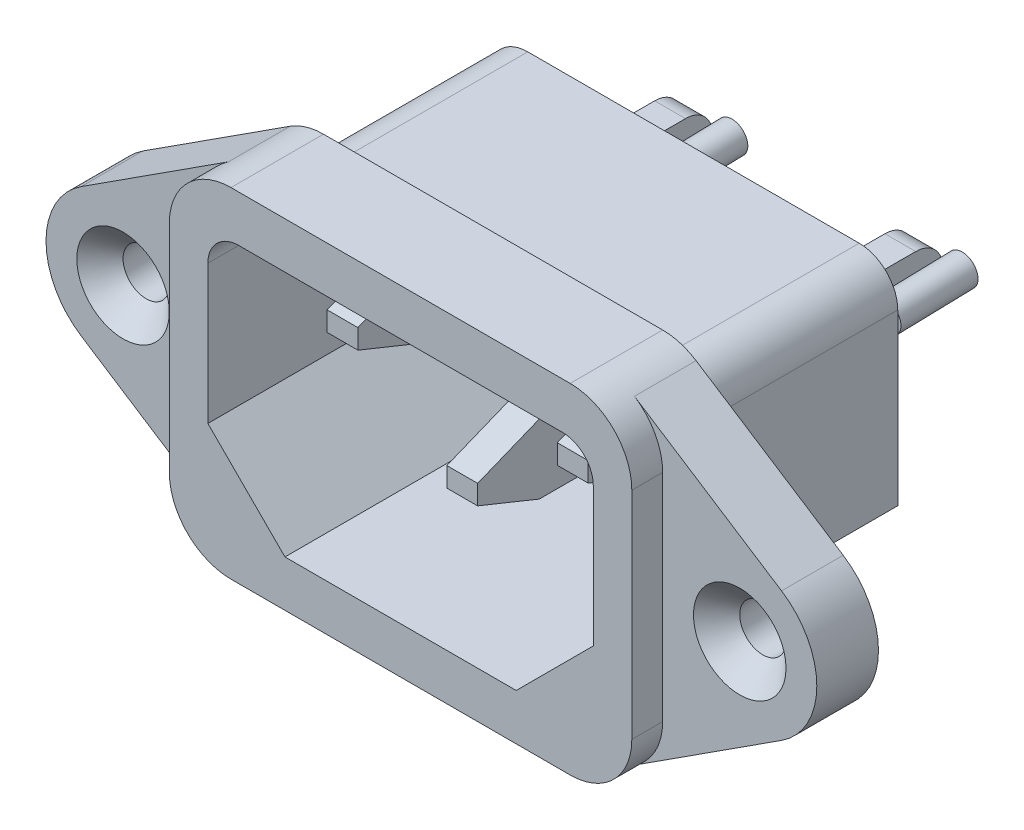
from build123d import *

# Parameters (mm, degrees)
BASE_DEPTH                       = 4
BOSS_EXTRUDE2_DEPTH              = 2
SKETCH3_W                        = 26.5
SKETCH3_H                        = 18.5
BOSS_EXTRUDE3_DEPTH              = 13
SKETCH4_W                        = 25
SKETCH4_H                        = 16
CUT_EXTRUDE1_DEPTH               = 17
GND_DEPTH                        = 2
EXTRUDE_L_DEPTH                  = 2
EXTRUDE_N_DEPTH                  = 2
MOUNT_3_0_3_DIAMETER_HOLE1_D     = 3
MOUNT_3_0_3_DIAMETER_HOLE1_DEPTH = 25
CHAMFER1_SIZE                    = 5
CHAMFER2_SIZE                    = 1.692162145
CHAMFER2_PART_2_SIZE             = 1.692162145
CHAMFER2_PART_3_SIZE             = 1.692162145
CHAMFER3_SIZE                    = 1.5
FILLET1_R                        = 2
FILLET2_R                        = 2.5
SOLDER_DEPTH                     = 2
SOLDER_DEPTH_BACK                = 3
SKETCH13_R                       = 1
SOLDER_2_DEPTH                   = 2
SOLDER_2_DEPTH_BACK              = 3
SOLDER_3_DEPTH                   = 2
SOLDER_3_DEPTH_BACK              = 3


with BuildPart() as part:
    # Sketch1 → Base (new body)
    with BuildSketch(Plane(origin=(0, 0, 0), x_dir=(-1, 0, 0), z_dir=(0, 0, -1))):
        with BuildLine():
            Line((-13.169375903, 10.360626161), (-22.711719879, 4.200782701))
            ThreePointArc((-22.711719879, 4.200782701), (-25, 0), (-22.711719879, -4.200782701))
            Line((-22.711719879, -4.200782701), (-13.169375903, -10.360626161))
            ThreePointArc((-13.169375903, -10.360626161), (-12.130817261, -10.83682842), (-11, -11))
            Line((-11, -11), (11, -11))
            ThreePointArc((11, -11), (12.130817261, -10.83682842), (13.169375903, -10.360626161))
            Line((13.169375903, -10.360626161), (22.711719879, -4.200782701))
            ThreePointArc((22.711719879, -4.200782701), (25, 0), (22.711719879, 4.200782701))
            Line((22.711719879, 4.200782701), (13.169375903, 10.360626161))
            ThreePointArc((13.169375903, 10.360626161), (12.130817261, 10.83682842), (11, 11))
            Line((11, 11), (-11, 11))
            ThreePointArc((-11, 11), (-12.130817261, 10.83682842), (-13.169375903, 10.360626161))
        make_face()
    extrude(amount=-BASE_DEPTH)

    # Sketch2 → Boss-Extrude2 (add)
    with BuildSketch(Plane.XY.offset(4)):
        with BuildLine():
            Line((11, -11), (-11, -11))
            ThreePointArc((-11, -11), (-13.828427125, -9.828427125), (-15, -7))
            Line((-15, -7), (-15, 7))
            ThreePointArc((-15, 7), (-13.828427125, 9.828427125), (-11, 11))
            Line((-11, 11), (11, 11))
            ThreePointArc((11, 11), (13.828427125, 9.828427125), (15, 7))
            Line((15, 7), (15, -7))
            ThreePointArc((15, -7), (13.828427125, -9.828427125), (11, -11))
        make_face()
    extrude(amount=BOSS_EXTRUDE2_DEPTH)

    # Sketch3 → Boss-Extrude3 (add)
    with BuildSketch(Plane(origin=(0, 0, 0), x_dir=(-1, 0, 0), z_dir=(0, 0, -1))):
        Rectangle(SKETCH3_W, SKETCH3_H)
    extrude(amount=BOSS_EXTRUDE3_DEPTH)

    # Sketch4 → Cut-Extrude1 (cut)
    with BuildSketch(Plane.XY.offset(6)):
        Rectangle(SKETCH4_W, SKETCH4_H)
    extrude(amount=-CUT_EXTRUDE1_DEPTH, mode=Mode.SUBTRACT)

    # Sketch5 → GND (add)
    with BuildSketch(Plane(origin=(1, 0, 0), x_dir=(0, 0, -1), z_dir=(1, 0, 0))):
        with BuildLine():
            Line((2, 0.000898958), (-3.56894542, -2.249101042))
            Line((-3.56894542, -2.249101042), (2, -4.499101042))
            Line((2, -4.499101042), (13, -4.499101042))
            Line((13, -4.499101042), (13, -3.867648726))
            Line((13, -3.867648726), (19.381452315, -3.867648726))
            ThreePointArc((19.381452315, -3.867648726), (21, -2.249101042), (19.381452315, -0.630553357))
            Line((19.381452315, -0.630553357), (13, -0.630553357))
            Line((13, -0.630553357), (13, 0.000898958))
            Line((13, 0.000898958), (2, 0.000898958))
        make_face()
    extrude(amount=-GND_DEPTH)

    # Sketch6 → Extrude L (add)
    with BuildSketch(Plane(origin=(-6.767244159, 0, 0), x_dir=(0, 0, -1), z_dir=(1, 0, 0))):
        with BuildLine():
            Line((2, 4.865233769), (-3.56894542, 2.615233769))
            Line((-3.56894542, 2.615233769), (2, 0.365233769))
            Line((2, 0.365233769), (12.665711597, 0.365233769))
            Line((12.665711597, 0.365233769), (12.665711597, 0.865233769))
            Line((12.665711597, 0.865233769), (19.25, 0.865233769))
            ThreePointArc((19.25, 0.865233769), (21, 2.615233769), (19.25, 4.365233769))
            Line((19.25, 4.365233769), (12.665711597, 4.365233769))
            Line((12.665711597, 4.365233769), (12.665711597, 4.865233769))
            Line((12.665711597, 4.865233769), (2, 4.865233769))
        make_face()
    extrude(amount=-EXTRUDE_L_DEPTH)

    # Sketch7 → Extrude N (add)
    with BuildSketch(Plane(origin=(8.165740402, 0, 0), x_dir=(0, 0, -1), z_dir=(1, 0, 0))):
        with BuildLine():
            Line((2, 4.865233769), (-3.56894542, 2.615233769))
            Line((-3.56894542, 2.615233769), (2, 0.365233769))
            Line((2, 0.365233769), (13, 0.365233769))
            Line((13, 0.365233769), (13, 0.865233769))
            Line((13, 0.865233769), (19.25, 0.865233769))
            ThreePointArc((19.25, 0.865233769), (21, 2.615233769), (19.25, 4.365233769))
            Line((19.25, 4.365233769), (13, 4.365233769))
            Line((13, 4.365233769), (13, 4.865233769))
            Line((13, 4.865233769), (2, 4.865233769))
        make_face()
    extrude(amount=-EXTRUDE_N_DEPTH)

    # Mount Ø3.0 (3) Diameter Hole1
    with Locations(Plane.XY.offset(4)):
        with Locations((-20, 0), (20, 0)):
            Hole(MOUNT_3_0_3_DIAMETER_HOLE1_D / 2, depth=MOUNT_3_0_3_DIAMETER_HOLE1_DEPTH)

    # Chamfer1
    chamfer1_edges = [part.edges().sort_by_distance(p)[0] for p in [
        (13.25, -9.25, -6.5),
        (-13.25, -9.25, -6.5),
        (12.5, -8, -2.5),
        (-12.5, -8, -2.5),
    ]]
    chamfer(chamfer1_edges, length=CHAMFER1_SIZE)

    # Chamfer2
    chamfer2_edges = [part.edges().sort_by_distance(p)[0] for p in [
        (0, -2.249101042, 3.56894542),
    ]]
    chamfer(chamfer2_edges, length=CHAMFER2_SIZE)

    # Chamfer2 part 2
    chamfer2_part_2_edges = [part.edges().sort_by_distance(p)[0] for p in [
        (-7.767244159, 2.615233769, 3.56894542),
    ]]
    chamfer(chamfer2_part_2_edges, length=CHAMFER2_PART_2_SIZE)

    # Chamfer2 part 3
    chamfer2_part_3_edges = [part.edges().sort_by_distance(p)[0] for p in [
        (7.165740402, 2.615233769, 3.56894542),
    ]]
    chamfer(chamfer2_part_3_edges, length=CHAMFER2_PART_3_SIZE)

    # Chamfer3
    chamfer3_edges = [part.edges().sort_by_distance(p)[0] for p in [
        (-18.5, 0, 4),
        (21.5, 0, 4),
    ]]
    chamfer(chamfer3_edges, length=CHAMFER3_SIZE)

    # Fillet1
    fillet1_edges = [part.edges().sort_by_distance(p)[0] for p in [
        (12.5, 8, -2.5),
        (-12.5, 8, -2.5),
    ]]
    fillet(fillet1_edges, radius=FILLET1_R)

    # Fillet2
    fillet2_edges = [part.edges().sort_by_distance(p)[0] for p in [
        (-13.25, 9.25, -6.5),
        (13.25, 9.25, -6.5),
    ]]
    fillet(fillet2_edges, radius=FILLET2_R)


with BuildPart() as body_2:
    # Sketch13 → Solder (new, two sides: drawn at the far end of the back side and taken through both)
    with BuildSketch(Plane(origin=(0, -0.008351756, -19.365080553), x_dir=(-1, 0, 0), z_dir=(0, 0.026303529294603365, -0.9996540023161254)).offset(-SOLDER_DEPTH_BACK)):
        with Locations((-9.165740402, 2.790101854)):
            Circle(SKETCH13_R)
    extrude(amount=SOLDER_DEPTH + SOLDER_DEPTH_BACK)


with BuildPart() as body_3:
    # Sketch13 → Solder 2 (new, two sides: drawn at the far end of the back side and taken through both)
    with BuildSketch(Plane(origin=(0, -0.008351756, -19.365080553), x_dir=(-1, 0, 0), z_dir=(0, 0.026303529294603365, -0.9996540023161254)).offset(-SOLDER_2_DEPTH_BACK)):
        with Locations((5.767244159, 2.790101854)):
            Circle(SKETCH13_R)
    extrude(amount=SOLDER_2_DEPTH + SOLDER_2_DEPTH_BACK)


with BuildPart() as body_4:
    # Sketch13 → Solder 3 (new, two sides: drawn at the far end of the back side and taken through both)
    with BuildSketch(Plane(origin=(0, -0.008351756, -19.365080553), x_dir=(-1, 0, 0), z_dir=(0, 0.026303529294603365, -0.9996540023161254)).offset(-SOLDER_3_DEPTH_BACK)):
        with Locations((-2, -2.072549909)):
            Circle(SKETCH13_R)
    extrude(amount=SOLDER_3_DEPTH + SOLDER_3_DEPTH_BACK)


solid = Compound([part.part, body_2.part, body_3.part, body_4.part])
